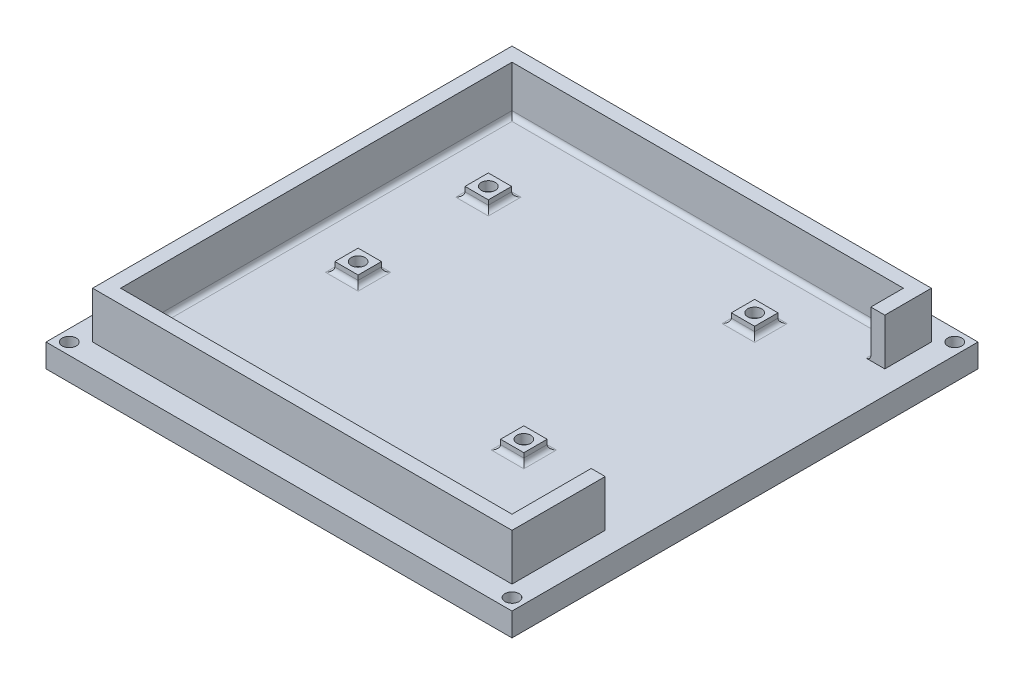
from build123d import *

# Parameters (mm, degrees)
SKETCH1_W            = 100
SKETCH1_H            = 100
BOSS_EXTRUDE1_DEPTH  = 5
SKETCH2_W            = 90
SKETCH2_H            = 90
SKETCH2_W_2          = 84
SKETCH2_H_2          = 84
BOSS_EXTRUDE2_DEPTH  = 10
SKETCH4_W            = 5
SKETCH4_H            = 5
SKETCH4_R            = 1.5
BOSS_EXTRUDE3_DEPTH  = 2
FILLET1_R            = 1
SKETCH5_W            = 60
SKETCH5_H            = 10
CUT_EXTRUDE1_DEPTH   = 5
SKETCH6_R            = 1.5
CUT_EXTRUDE2_DEPTH   = 5
LPATTERN1_COUNT      = 2
LPATTERN1_PITCH      = 95
LPATTERN1_COUNT_DIR2 = 2
LPATTERN1_PITCH_DIR2 = 95


with BuildPart() as part:
    # Sketch1 → Boss-Extrude1 (new body)
    with BuildSketch(Plane(origin=(0, 0, 0), x_dir=(1, 0, 0), z_dir=(0, 1, 0))):
        with Locations((50, 50)):
            Rectangle(SKETCH1_W, SKETCH1_H)
    extrude(amount=BOSS_EXTRUDE1_DEPTH)

    # Sketch2 → Boss-Extrude2 (add)
    with BuildSketch(Plane(origin=(0, 5, 0), x_dir=(1, 0, 0), z_dir=(0, 1, 0))):
        with Locations((50, 50)):
            Rectangle(SKETCH2_W, SKETCH2_H)
        with Locations((50, 50)):
            Rectangle(SKETCH2_W_2, SKETCH2_H_2, mode=Mode.SUBTRACT)
    extrude(amount=BOSS_EXTRUDE2_DEPTH)

    # Sketch4 → Boss-Extrude3 (add)
    with BuildSketch(Plane(origin=(0, 5, 0), x_dir=(1, 0, 0), z_dir=(0, 1, 0))):
        with Locations((20.54, 46.44)):
            Rectangle(SKETCH4_W, SKETCH4_H)
        with Locations((20.54, 46.44)):
            Circle(SKETCH4_R, mode=Mode.SUBTRACT)
        with Locations((20.54, 74.38)):
            Rectangle(SKETCH4_W, SKETCH4_H)
        with Locations((20.54, 74.38)):
            Circle(SKETCH4_R, mode=Mode.SUBTRACT)
        with Locations((72.61, 79.46)):
            Rectangle(SKETCH4_W, SKETCH4_H)
        with Locations((72.61, 79.46)):
            Circle(SKETCH4_R, mode=Mode.SUBTRACT)
        with Locations((71.34, 31.2)):
            Rectangle(SKETCH4_W, SKETCH4_H)
        with Locations((71.34, 31.2)):
            Circle(SKETCH4_R, mode=Mode.SUBTRACT)
    extrude(amount=BOSS_EXTRUDE3_DEPTH)

    # Fillet1
    fillet1_edges = [part.edges().sort_by_distance(p)[0] for p in [
        (8, 5, -50),
        (50, 5, -8),
        (92, 5, -50),
        (50, 5, -92),
        (23.04, 5, -74.38),
        (20.54, 5, -76.88),
        (18.04, 5, -74.38),
        (20.54, 5, -71.88),
        (75.11, 5, -79.46),
        (72.61, 5, -81.96),
        (70.11, 5, -79.46),
        (72.61, 5, -76.96),
        (23.04, 5, -46.44),
        (20.54, 5, -48.94),
        (18.04, 5, -46.44),
        (20.54, 5, -43.94),
        (73.84, 5, -31.2),
        (71.34, 5, -33.7),
        (68.84, 5, -31.2),
        (71.34, 5, -28.7),
    ]]
    fillet(fillet1_edges, radius=FILLET1_R)

    # Sketch5 → Cut-Extrude1 (cut)
    with BuildSketch(Plane(origin=(95, 0, 0), x_dir=(0, 0, -1), z_dir=(1, 0, 0))):
        with Locations((55, 10)):
            Rectangle(SKETCH5_W, SKETCH5_H)
    extrude(amount=-CUT_EXTRUDE1_DEPTH, mode=Mode.SUBTRACT)

    # Sketch6 → Cut-Extrude2 (cut)
    with BuildSketch(Plane.XZ):
        with Locations((2.5, -2.5)):
            Circle(SKETCH6_R)
    cut_extrude2 = extrude(amount=-CUT_EXTRUDE2_DEPTH, mode=Mode.SUBTRACT)

    # LPattern1: Cut-Extrude2 2 × 2
    with Locations(*[(i * LPATTERN1_PITCH, 0, -j * LPATTERN1_PITCH_DIR2) for i in range(LPATTERN1_COUNT) for j in range(LPATTERN1_COUNT_DIR2) if (i, j) != (0, 0)]):
        add(cut_extrude2, mode=Mode.SUBTRACT)


solid = part.part
